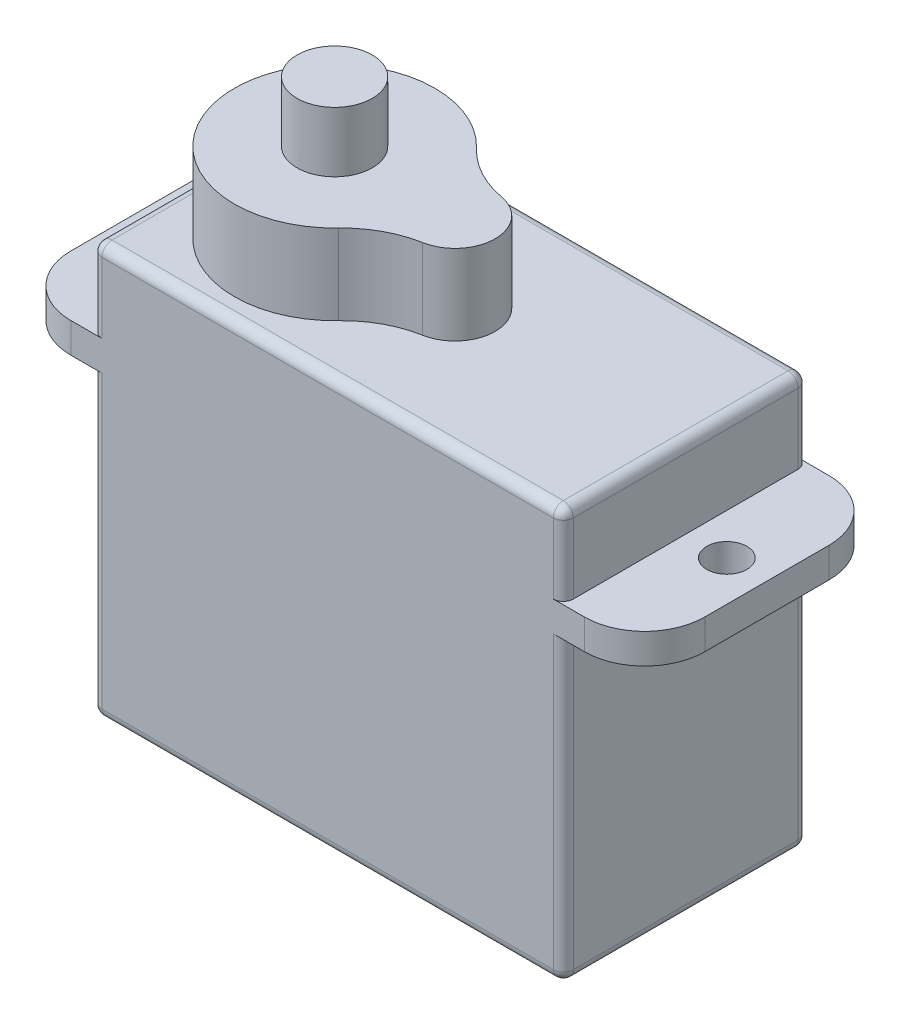
from build123d import *

# Parameters (mm, degrees)
ESQUISSE1_W        = 23.5
ESQUISSE1_H        = 20.5
CORPS_DEPTH        = 6.1
COQUE1_T           = 2
PIVOT_SORTIE_DEPTH = 24.5
ESQUISSE3_R        = 1.875
AXE_SORTIE_DEPTH   = 3
ESQUISSE4_W        = 31.6
ESQUISSE4_H        = 12.2
ESQUISSE4_R        = 1
MIP_MAP_DEPTH      = 1.5
CONG_1_R           = 3
CONG_2_R           = 0.5


with BuildPart() as part:
    # Esquisse1 → corps (new body, symmetric)
    with BuildSketch(Plane.XY):
        with Locations((0, 10.25)):
            Rectangle(ESQUISSE1_W, ESQUISSE1_H)
    extrude(amount=CORPS_DEPTH, both=True)

    # Coque1 (no face opened: a closed hollow body)
    add(offset(amount=-COQUE1_T, mode=Mode.PRIVATE), mode=Mode.SUBTRACT)

    # Esquisse2 → pivot_sortie (add)
    with BuildSketch(Plane(origin=(0, 0, 0), x_dir=(1, 0, 0), z_dir=(0, 1, 0))):
        with BuildLine():
            ThreePointArc((-2.125, 3.443744328), (-10.75, 0), (-2.125, -3.443744328))
            ThreePointArc((-2.125, -3.443744328), (-0.876409356, -2.488320716), (0.607142857, -1.967853902))
            ThreePointArc((0.607142857, -1.967853902), (2.25, 0), (0.607142857, 1.967853902))
            ThreePointArc((0.607142857, 1.967853902), (-0.876409356, 2.488320716), (-2.125, 3.443744328))
        make_face()
    extrude(amount=PIVOT_SORTIE_DEPTH)

    # Esquisse3 → axe_sortie (add)
    with BuildSketch(Plane(origin=(0, 24.5, 0), x_dir=(1, 0, 0), z_dir=(0, 1, 0))):
        with Locations((-5.75, 0)):
            Circle(ESQUISSE3_R)
    extrude(amount=AXE_SORTIE_DEPTH)

    # Esquisse4 → MIP_MAP (add)
    with BuildSketch(Plane.XZ.offset(-15)):
        Rectangle(ESQUISSE4_W, ESQUISSE4_H)
        with Locations((-13.8, 0)):
            Circle(ESQUISSE4_R, mode=Mode.SUBTRACT)
        with Locations((13.8, 0)):
            Circle(ESQUISSE4_R, mode=Mode.SUBTRACT)
    extrude(amount=-MIP_MAP_DEPTH)

    # Congé1
    cong_1_edges = [part.edges().sort_by_distance(p)[0] for p in [
        (15.8, 15.75, -6.1),
        (-15.8, 15.75, 6.1),
        (15.8, 15.75, 6.1),
        (-15.8, 15.75, -6.1),
    ]]
    fillet(cong_1_edges, radius=CONG_1_R)

    # Congé2
    cong_2_edges = [part.edges().sort_by_distance(p)[0] for p in [
        (11.75, 7.5, 6.1),
        (0, 20.5, 6.1),
        (-11.75, 18.5, 6.1),
        (0, 20.5, -6.1),
        (11.75, 7.5, -6.1),
        (0, 0, -6.1),
        (-11.75, 18.5, -6.1),
        (0, 0, 6.1),
        (-11.75, 20.5, 0),
        (11.75, 20.5, 0),
        (11.75, 0, 0),
        (-11.75, 0, 0),
        (-11.75, 7.5, -6.1),
        (11.75, 18.5, -6.1),
        (-11.75, 7.5, 6.1),
        (11.75, 18.5, 6.1),
    ]]
    fillet(cong_2_edges, radius=CONG_2_R)


solid = part.part
